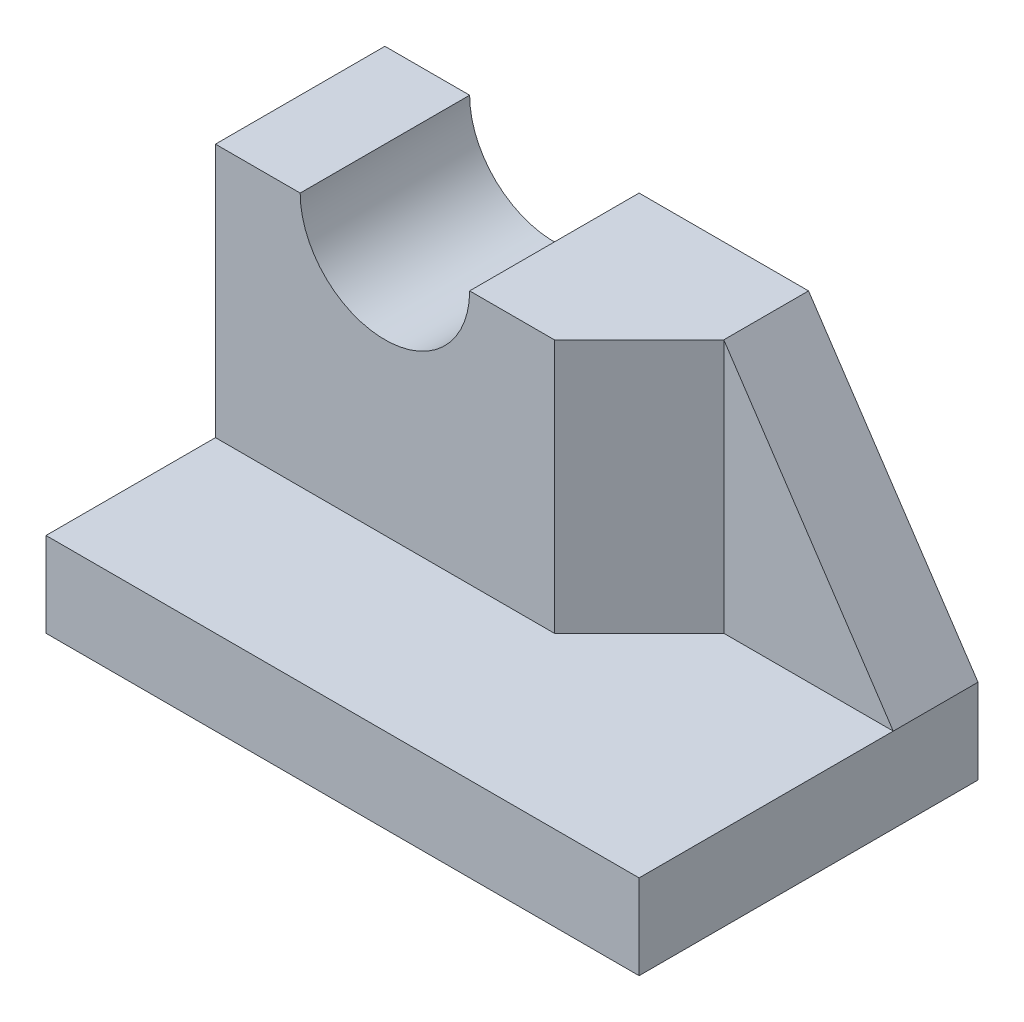
from build123d import *

# Parameters (mm, degrees)
SKETCH_1_W          = 35
SKETCH_1_H          = 20
EXTRUDE_1_DEPTH     = 5
EXTRUDE_2_DEPTH     = 20
CUT_EXTRUDE_1_DEPTH = 20


with BuildPart() as part:
    # 草圖1 → 填料-伸長1 (new body)
    with BuildSketch(Plane(origin=(0, 0, 0), x_dir=(1, 0, 0), z_dir=(0, 1, 0))):
        Rectangle(SKETCH_1_W, SKETCH_1_H)
    extrude(amount=EXTRUDE_1_DEPTH)

    # 草圖1<3> → 填料-伸長2 (add)
    with BuildSketch(Plane(origin=(0, 0, 0), x_dir=(1, 0, 0), z_dir=(0, 1, 0))):
        Polygon((2.5, 0), (7.5, 5), (17.5, 5), (17.5, 10), (-17.5, 10), (-17.5, 0), align=None)
    extrude(amount=EXTRUDE_2_DEPTH)

    # 草圖2 → 除料-伸長1 (cut)
    with BuildSketch(Plane.XY):
        with BuildLine():
            Line((-12.5, 20), (-2.5, 20))
            ThreePointArc((-2.5, 20), (-7.5, 15), (-12.5, 20))
        make_face()
        Polygon((17.5, 5), (7.5, 20), (17.5, 20), align=None)
    extrude(amount=-CUT_EXTRUDE_1_DEPTH, mode=Mode.SUBTRACT)


solid = part.part
